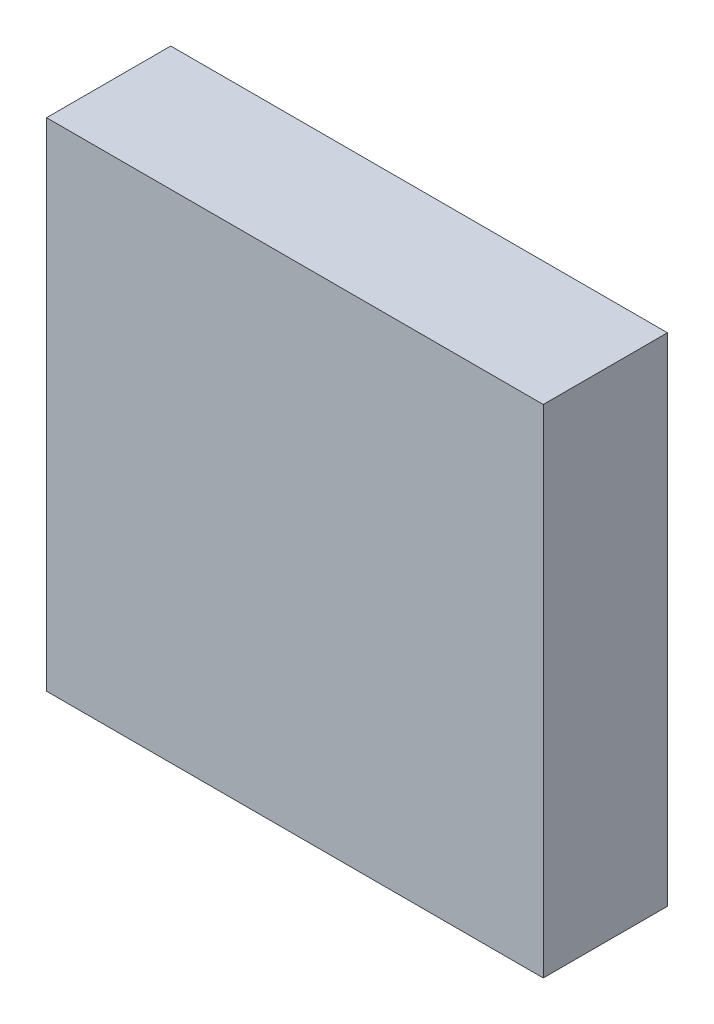
from build123d import *

# Parameters (mm, degrees)
SKETCH1_W           = 304.8
SKETCH1_H           = 304.8
BOSS_EXTRUDE1_DEPTH = 76.2
SKETCH2_R           = 3.175
CUT_EXTRUDE1_DEPTH  = 2.54


with BuildPart() as part:
    # Sketch1 → Boss-Extrude1 (new body)
    with BuildSketch(Plane.XY):
        Rectangle(SKETCH1_W, SKETCH1_H)
    extrude(amount=BOSS_EXTRUDE1_DEPTH)

    # Sketch2 → Cut-Extrude1 (cut)
    with BuildSketch(Plane(origin=(0, 0, 0), x_dir=(-1, 0, 0), z_dir=(0, 0, -1))):
        Circle(SKETCH2_R)
    extrude(amount=-CUT_EXTRUDE1_DEPTH, mode=Mode.SUBTRACT)


solid = part.part
